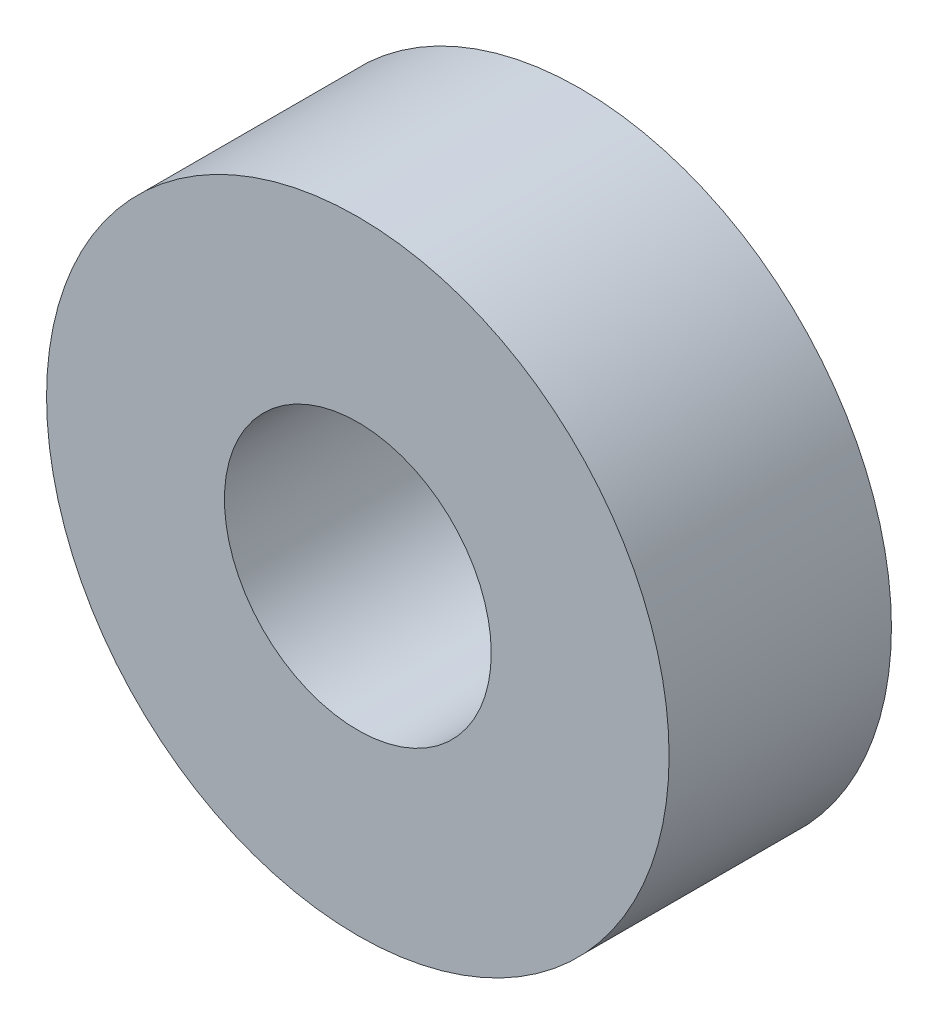
from build123d import *

# Parameters (mm, degrees)
SKETCH1_R           = 7
SKETCH1_R_2         = 3
BOSS_EXTRUDE1_DEPTH = 2.5


with BuildPart() as part:
    # Sketch1 → Boss-Extrude1 (new body, symmetric)
    with BuildSketch(Plane.XY):
        Circle(SKETCH1_R)
        Circle(SKETCH1_R_2, mode=Mode.SUBTRACT)
    extrude(amount=BOSS_EXTRUDE1_DEPTH, both=True)


solid = part.part
